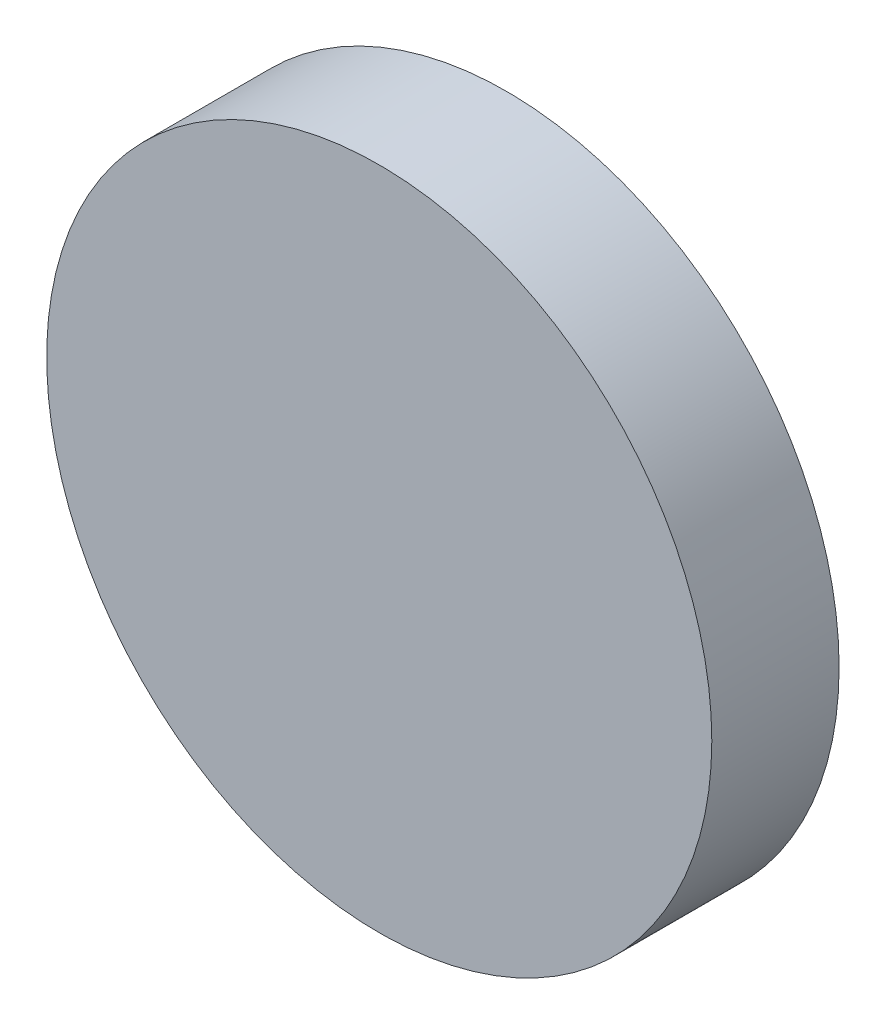
from build123d import *

# Parameters (mm, degrees)
SKETCH1_R           = 128
BOSS_EXTRUDE1_DEPTH = 49


with BuildPart() as part:
    # Sketch1 → Boss-Extrude1 (new body)
    with BuildSketch(Plane.XY):
        Circle(SKETCH1_R)
    extrude(amount=BOSS_EXTRUDE1_DEPTH)


solid = part.part
